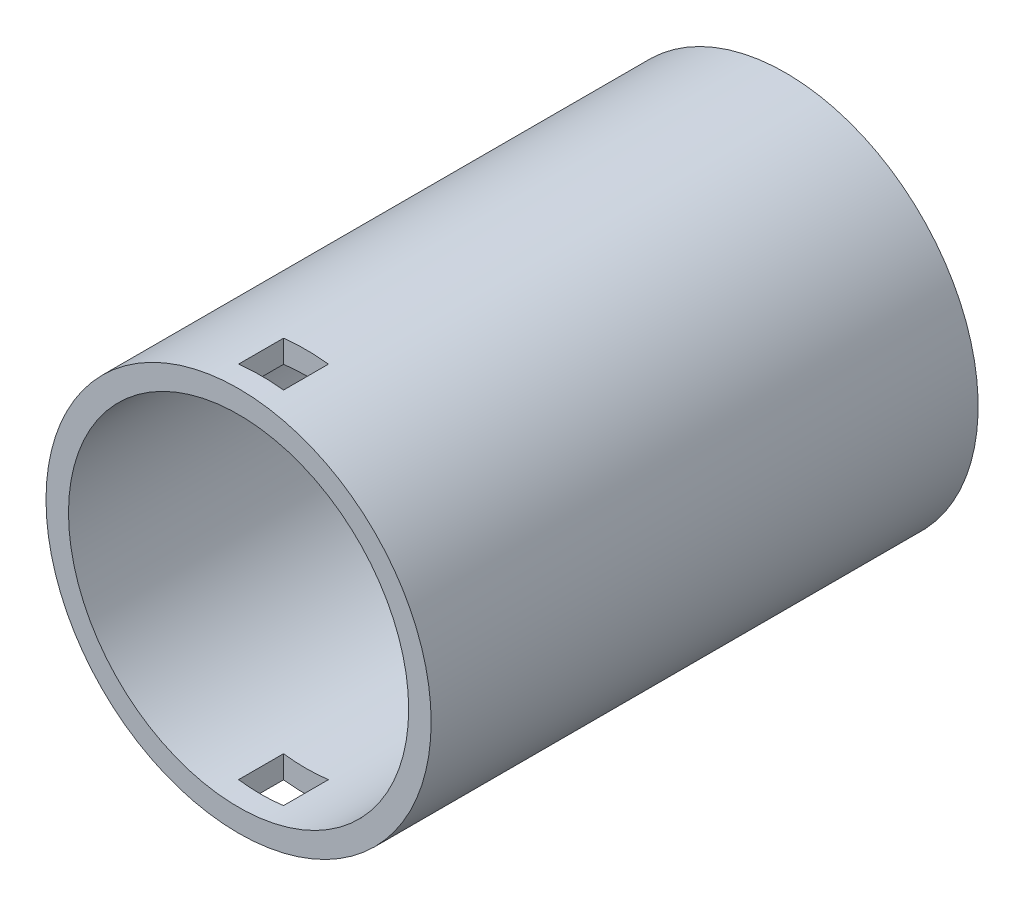
from build123d import *

# Parameters (mm, degrees)
ESBO_O1_R                  = 12.85
ESBO_O1_R_2                = 11.35
RESSALTO_EXTRUS_O1_DEPTH   = 35
ESBO_O2_R                  = 12.85
RESSALTO_EXTRUS_O2_DEPTH   = 1.5
ESBO_O3_W                  = 3
ESBO_O3_H                  = 3
CORTE_EXTRUS_O1_DEPTH      = 13.85
CORTE_EXTRUS_O1_DEPTH_BACK = 13.85


with BuildPart() as part:
    # Esboço1 → Ressalto-extrusão1 (new body)
    with BuildSketch(Plane.XY):
        Circle(ESBO_O1_R)
        Circle(ESBO_O1_R_2, mode=Mode.SUBTRACT)
    extrude(amount=RESSALTO_EXTRUS_O1_DEPTH)

    # Esboço2 → Ressalto-extrusão2 (add)
    with BuildSketch(Plane(origin=(0, 0, 0), x_dir=(-1, 0, 0), z_dir=(0, 0, -1))):
        Circle(ESBO_O2_R)
    extrude(amount=RESSALTO_EXTRUS_O2_DEPTH)

    # Esboço3 → Corte-extrusão1 (cut, two sides)
    with BuildSketch(Plane(origin=(0, 0, 0), x_dir=(1, 0, 0), z_dir=(0, 1, 0))) as corte_extrus_o1_sk:
        with Locations((0, -32)):
            Rectangle(ESBO_O3_W, ESBO_O3_H)
    extrude(amount=CORTE_EXTRUS_O1_DEPTH, mode=Mode.SUBTRACT)
    extrude(corte_extrus_o1_sk.sketch, amount=-CORTE_EXTRUS_O1_DEPTH_BACK, mode=Mode.SUBTRACT)


solid = part.part
